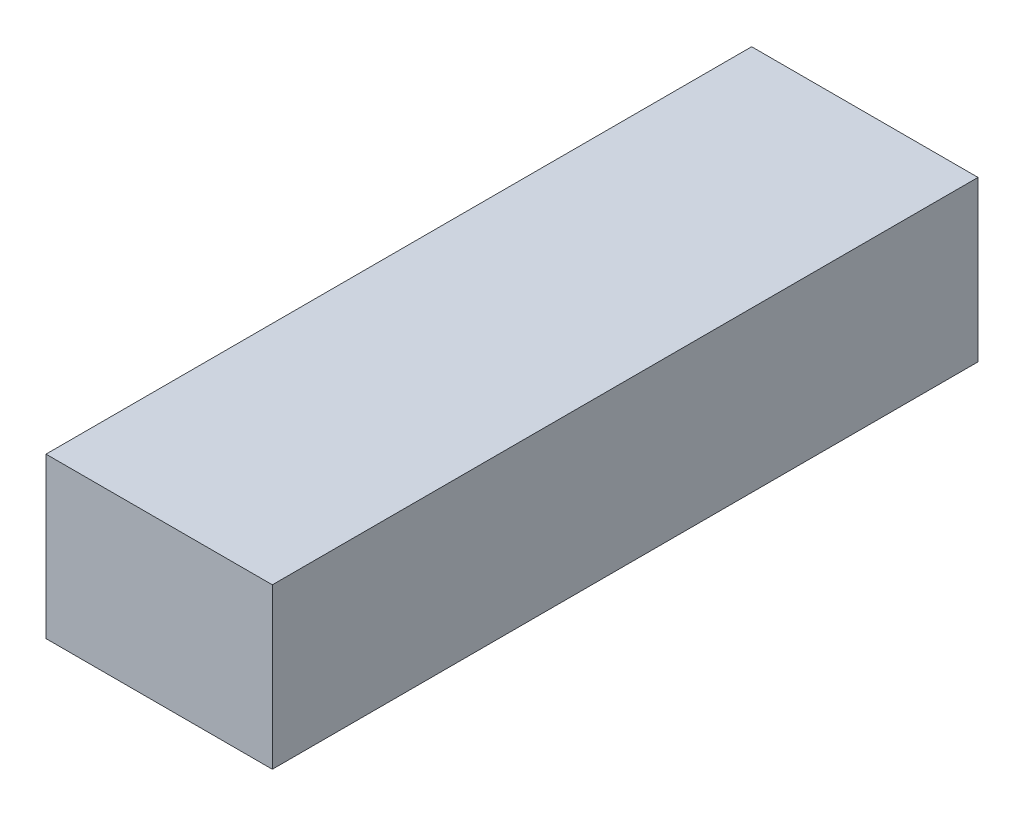
from build123d import *

# Parameters (mm, degrees)
SKETCH1_W           = 34
SKETCH1_H           = 106
BOSS_EXTRUDE1_DEPTH = 24


with BuildPart() as part:
    # Sketch1 → Boss-Extrude1 (new body)
    with BuildSketch(Plane(origin=(0, 0, 0), x_dir=(1, 0, 0), z_dir=(0, 1, 0))):
        Rectangle(SKETCH1_W, SKETCH1_H)
    extrude(amount=BOSS_EXTRUDE1_DEPTH)


solid = part.part
